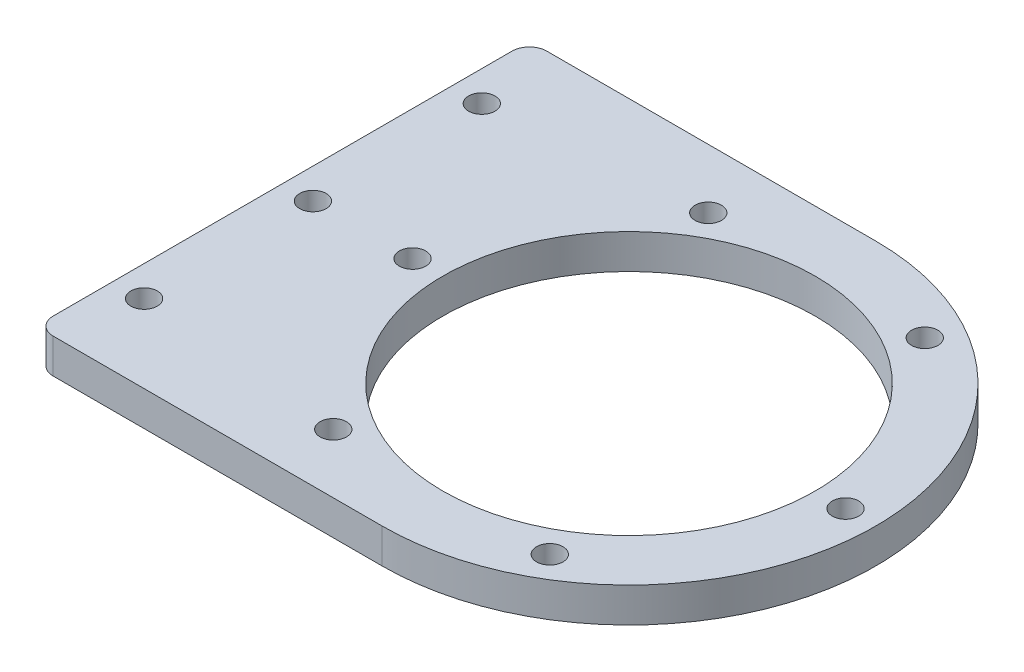
from build123d import *

# Parameters (mm, degrees)
EXTRUDE_1_DEPTH     = 4
SKETCH_2_R          = 21.5
CUT_EXTRUDE_1_DEPTH = 5
SKETCH_4_R          = 1.525
CUT_EXTRUDE_3_DEPTH = 5
SKETCH_5_R          = 1.525
CUT_EXTRUDE_4_DEPTH = 5
SKETCH_6_W          = 1
SKETCH_6_H          = 57
EXTRUDE_2_DEPTH     = 4
FILLET_1_R          = 2


with BuildPart() as part:
    # 草图1 → 凸台-拉伸1 (new body)
    with BuildSketch(Plane(origin=(0, 0, 0), x_dir=(1, 0, 0), z_dir=(0, 1, 0))):
        with BuildLine():
            ThreePointArc((19.5, 28.5), (-9, 0), (19.5, -28.5))
            Line((19.5, -28.5), (19.5, 28.5))
        make_face()
        with BuildLine():
            Line((19.5, 28.5), (19.5, -28.5))
            ThreePointArc((19.5, -28.5), (39.652543264, -20.152543264), (48, 0))
            ThreePointArc((48, 0), (39.652543264, 20.152543264), (19.5, 28.5))
        make_face()
        with BuildLine():
            Line((-19.5, 28.5), (-19.5, -28.5))
            Line((-19.5, -28.5), (19.5, -28.5))
            ThreePointArc((19.5, -28.5), (-9, 0), (19.5, 28.5))
            Line((19.5, 28.5), (-19.5, 28.5))
        make_face()
    extrude(amount=EXTRUDE_1_DEPTH)

    # 草图2 → 切除-拉伸1 (cut, through all)
    with BuildSketch(Plane(origin=(0, 4, 0), x_dir=(1, 0, 0), z_dir=(0, 1, 0))):
        with Locations((19.5, 0)):
            Circle(SKETCH_2_R)
    extrude(amount=-CUT_EXTRUDE_1_DEPTH, mode=Mode.SUBTRACT)

    # 草图4 → 切除-拉伸3 (cut, through all)
    with BuildSketch(Plane(origin=(0, 4, 0), x_dir=(1, 0, 0), z_dir=(0, 1, 0))):
        with Locations((-5.5, 0)):
            Circle(SKETCH_4_R)
        with Locations((7, 21.650635095)):
            Circle(SKETCH_4_R)
        with Locations((32, 21.650635095)):
            Circle(SKETCH_4_R)
        with Locations((44.5, 0)):
            Circle(SKETCH_4_R)
        with Locations((32, -21.650635095)):
            Circle(SKETCH_4_R)
        with Locations((7, -21.650635095)):
            Circle(SKETCH_4_R)
    extrude(amount=-CUT_EXTRUDE_3_DEPTH, mode=Mode.SUBTRACT)

    # 草图5 → 切除-拉伸4 (cut, through all)
    with BuildSketch(Plane(origin=(0, 4, 0), x_dir=(1, 0, 0), z_dir=(0, 1, 0))):
        with Locations((-17, 19.5)):
            Circle(SKETCH_5_R)
        with Locations((-17, 0)):
            Circle(SKETCH_5_R)
        with Locations((-17, -19.5)):
            Circle(SKETCH_5_R)
    extrude(amount=-CUT_EXTRUDE_4_DEPTH, mode=Mode.SUBTRACT)

    # 草图6 → 凸台-拉伸2 (add)
    with BuildSketch(Plane(origin=(0, 4, 0), x_dir=(1, 0, 0), z_dir=(0, 1, 0))):
        with Locations((-20, 0)):
            Rectangle(SKETCH_6_W, SKETCH_6_H)
    extrude(amount=-EXTRUDE_2_DEPTH)

    # 圆角1
    fillet_1_edges = [part.edges().sort_by_distance(p)[0] for p in [
        (-20.5, 2, 28.5),
        (-20.5, 2, -28.5),
    ]]
    fillet(fillet_1_edges, radius=FILLET_1_R)


solid = part.part
